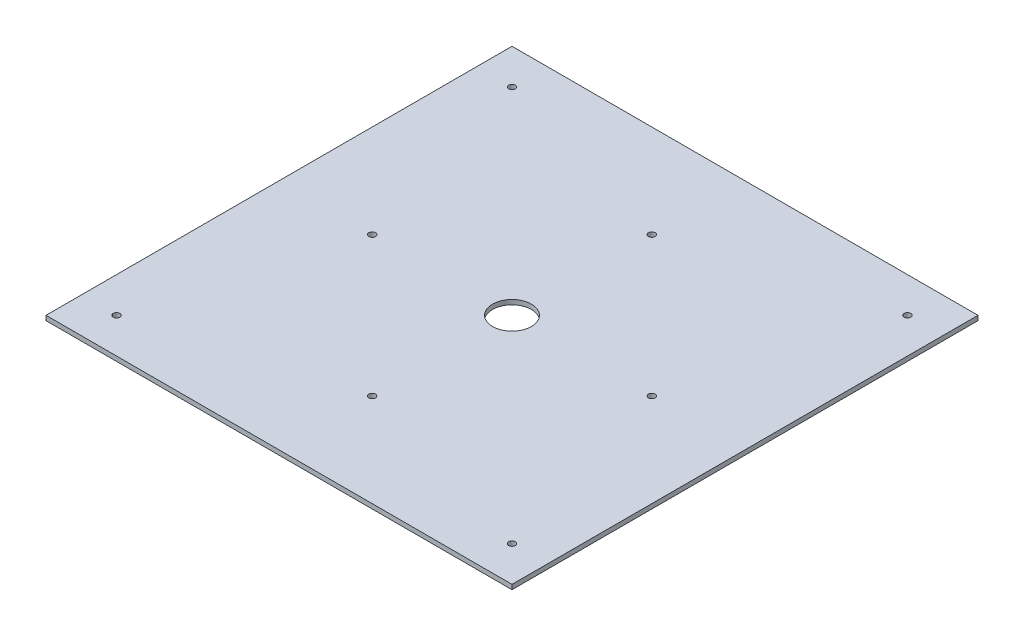
from build123d import *

# Parameters (mm, degrees)
SKETCH_1_W      = 300
SKETCH_1_H      = 300
SKETCH_1_R      = 12.5
SKETCH_1_R_2    = 2.15
EXTRUDE_1_DEPTH = 3


with BuildPart() as part:
    # 草图1 → 凸台-拉伸1 (new body)
    with BuildSketch(Plane(origin=(0, 0, 0), x_dir=(1, 0, 0), z_dir=(0, 1, 0))):
        with Locations((150, 150)):
            Rectangle(SKETCH_1_W, SKETCH_1_H)
        with Locations((150, 150)):
            Circle(SKETCH_1_R, mode=Mode.SUBTRACT)
        with Locations((22.720779386, 277.279220614)):
            Circle(SKETCH_1_R_2, mode=Mode.SUBTRACT)
        with Locations((277.279220614, 277.279220614)):
            Circle(SKETCH_1_R_2, mode=Mode.SUBTRACT)
        with Locations((277.279220614, 22.720779386)):
            Circle(SKETCH_1_R_2, mode=Mode.SUBTRACT)
        with Locations((22.720779386, 22.720779386)):
            Circle(SKETCH_1_R_2, mode=Mode.SUBTRACT)
        with Locations((150, 240)):
            Circle(SKETCH_1_R_2, mode=Mode.SUBTRACT)
        with Locations((240, 150)):
            Circle(SKETCH_1_R_2, mode=Mode.SUBTRACT)
        with Locations((150, 60)):
            Circle(SKETCH_1_R_2, mode=Mode.SUBTRACT)
        with Locations((60, 150)):
            Circle(SKETCH_1_R_2, mode=Mode.SUBTRACT)
    extrude(amount=EXTRUDE_1_DEPTH)


solid = part.part
